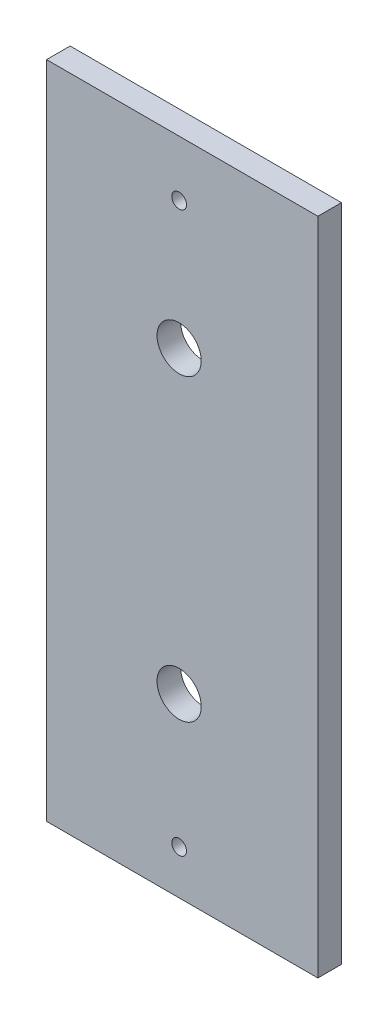
from build123d import *

# Parameters (mm, degrees)
MODEL_W             = 18.42
MODEL_H             = 44.79
MODEL_R             = 0.5
MODEL_R_2           = 1.5
BOSS_EXTRUDE1_DEPTH = 1.6


with BuildPart() as part:
    # Model → Boss-Extrude1 (new body)
    with BuildSketch(Plane.XY):
        with Locations((9.21, 22.395)):
            Rectangle(MODEL_W, MODEL_H)
        with Locations((9, 41)):
            Circle(MODEL_R, mode=Mode.SUBTRACT)
        with Locations((9, 32.32)):
            Circle(MODEL_R_2, mode=Mode.SUBTRACT)
        with Locations((9, 3)):
            Circle(MODEL_R, mode=Mode.SUBTRACT)
        with Locations((9, 12)):
            Circle(MODEL_R_2, mode=Mode.SUBTRACT)
    extrude(amount=BOSS_EXTRUDE1_DEPTH)


solid = part.part
